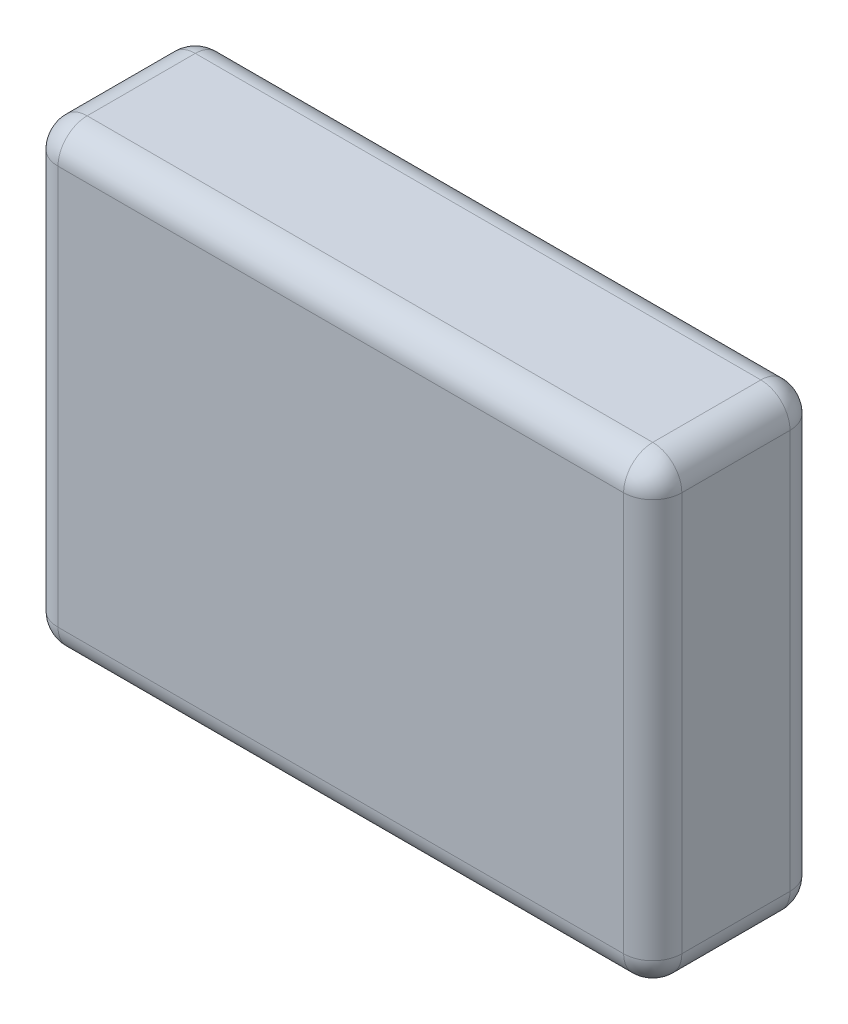
from build123d import *

# Parameters (mm, degrees)
SKETCH1_W           = 750
SKETCH1_H           = 550
BOSS_EXTRUDE1_DEPTH = 200
FILLET3_R           = 35


with BuildPart() as part:
    # Sketch1 → Boss-Extrude1 (new body)
    with BuildSketch(Plane.XY):
        with Locations((0, -102.728426396)):
            Rectangle(SKETCH1_W, SKETCH1_H)
    extrude(amount=BOSS_EXTRUDE1_DEPTH)

    # Fillet3
    fillet3_edges = [part.edges().sort_by_distance(p)[0] for p in [
        (-375, -102.728426396, 200),
        (0, -377.728426396, 200),
        (375, -102.728426396, 200),
        (0, -377.728426396, 0),
        (-375, -102.728426396, 0),
        (0, 172.271573604, 0),
        (375, -102.728426396, 0),
        (375, -377.728426396, 100),
        (-375, -377.728426396, 100),
        (-375, 172.271573604, 100),
        (375, 172.271573604, 100),
        (0, 172.271573604, 200),
    ]]
    fillet(fillet3_edges, radius=FILLET3_R)


solid = part.part
